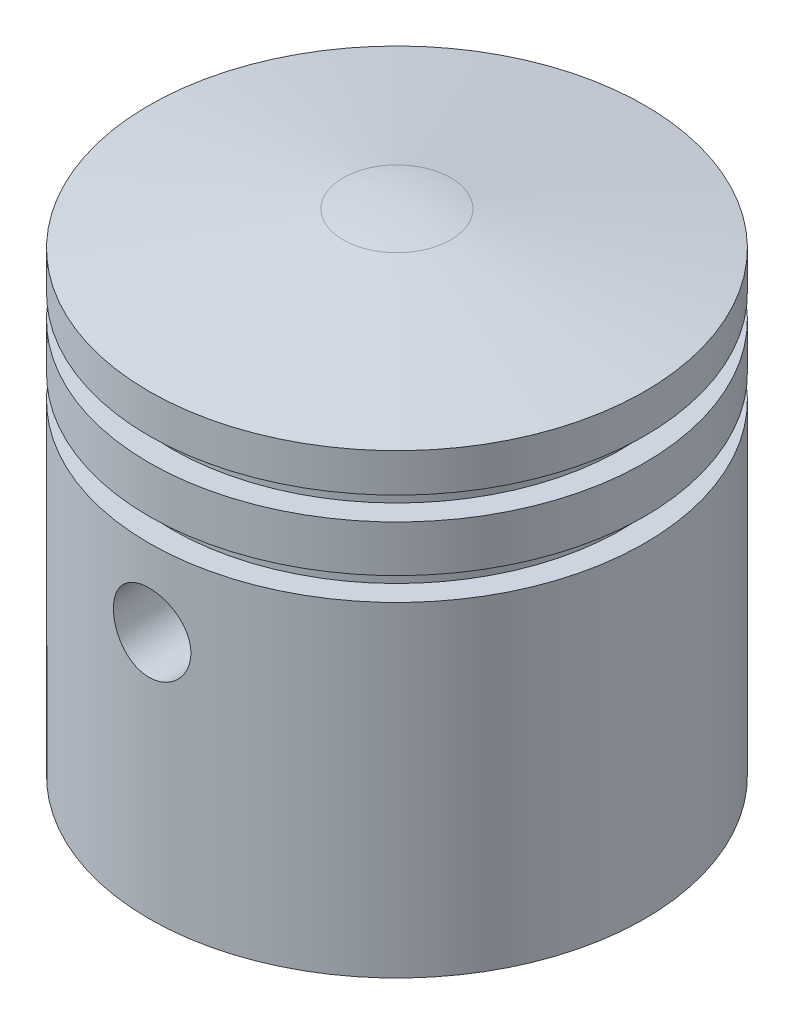
from build123d import *

# Parameters (mm, degrees)
SKETCH2_R               = 2.5
CUT_EXTRUDE1_DEPTH      = 17
CUT_EXTRUDE1_DEPTH_BACK = 17
SKETCH3_R               = 10
CUT_EXTRUDE2_DEPTH      = 24
SKETCH4_R               = 13
CUT_EXTRUDE3_DEPTH      = 10


with BuildPart() as part:
    # Sketch1 → Revolve1 (revolve)
    with BuildSketch(Plane.XY):
        with BuildLine():
            Line((0, 16), (0, -16))
            Line((0, -16), (16, -16))
            Line((16, -16), (16, 5))
            Line((16, 5), (14.5, 5))
            Line((14.5, 5), (14.5, 6.5))
            Line((14.5, 6.5), (16, 6.5))
            Line((16, 6.5), (16, 9.5))
            Line((16, 9.5), (14.5, 9.5))
            Line((14.5, 9.5), (14.5, 11))
            Line((14.5, 11), (16, 11))
            Line((16, 11), (16, 13.487300546))
            Line((16, 13.487300546), (3.472963553, 15.69615506))
            ThreePointArc((3.472963553, 15.69615506), (1.743114855, 15.923893962), (0, 16))
        make_face()
    revolve(axis=Axis((0, 16, 0), (0, -1, 0)))

    # Sketch2 → Cut-Extrude1 (cut, two sides)
    with BuildSketch(Plane.XY) as cut_extrude1_sk:
        Circle(SKETCH2_R)
    extrude(amount=CUT_EXTRUDE1_DEPTH, mode=Mode.SUBTRACT)
    extrude(cut_extrude1_sk.sketch, amount=-CUT_EXTRUDE1_DEPTH_BACK, mode=Mode.SUBTRACT)

    # Sketch3 → Cut-Extrude2 (cut)
    with BuildSketch(Plane.XZ.offset(16)):
        Circle(SKETCH3_R)
    extrude(amount=-CUT_EXTRUDE2_DEPTH, mode=Mode.SUBTRACT)

    # Sketch4 → Cut-Extrude3 (cut)
    with BuildSketch(Plane.XZ.offset(16)):
        Circle(SKETCH4_R)
    extrude(amount=-CUT_EXTRUDE3_DEPTH, mode=Mode.SUBTRACT)


solid = part.part
